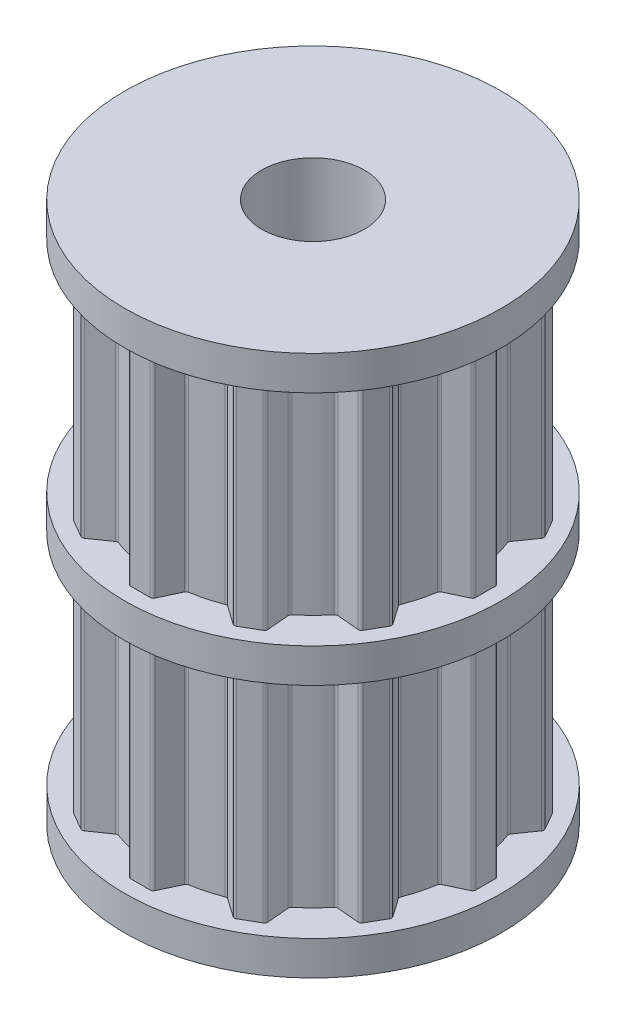
from build123d import *

# Parameters (mm, degrees)
SKETCH_1_R                       = 8.81
EXTRUDE_1_DEPTH                  = 13.8
EXTRUDE_5_DEPTH                  = 27.6
FILLET_1_R                       = 0.19
PATTERN_CIRCULAR_1_COUNT         = 12
FILLET_1_OF_PATTERN_CIRCULAR_1_R = 0.19
SKETCH_3_R                       = 11
EXTRUDE_3_DEPTH                  = 2
SKETCH_4_R                       = 11
EXTRUDE_4_DEPTH                  = 2
SKETCH_5_R                       = 3
CUT_EXTRUDE_1_DEPTH              = 32.6
EXTRUDE_START                    = -15.8
SKETCH_8_R                       = 11
EXTRUDE_6_DEPTH                  = 1


with BuildPart() as part:
    # 草圖1 → 填料-伸長1 (new body, symmetric)
    with BuildSketch(Plane(origin=(0, 0, 0), x_dir=(1, 0, 0), z_dir=(0, 1, 0))):
        Circle(SKETCH_1_R)
    extrude(amount=EXTRUDE_1_DEPTH, both=True)

    # 草圖7 → 填料-伸長5 (add, through all)
    with BuildSketch(Plane.XZ.offset(13.8)):
        Polygon((-1.751307658, -7.81), (1.751307658, -7.81), (0.692789274, -10.08), (-0.692789274, -10.08), align=None)
    extrude_5 = extrude(amount=-EXTRUDE_5_DEPTH)

    # 圓角1
    fillet_1_edges = [part.edges().sort_by_distance(p)[0] for p in [
        (-0.692789274, 0, -10.08),
        (1.332243049, 0, -8.708686954),
        (0.692789274, 0, -10.08),
        (-1.332243049, 0, -8.708686954),
    ]]
    fillet(fillet_1_edges, radius=FILLET_1_R)

    # 環狀複製排列1: 填料-伸長5 ×12 about axis
    pattern_circular_1_axis = Axis((0, 0, 0), (0, 1, 0))
    for i in range(1, PATTERN_CIRCULAR_1_COUNT):
        add(extrude_5.rotate(pattern_circular_1_axis, i * 360 / PATTERN_CIRCULAR_1_COUNT))

    # 圓角1 of 環狀複製排列1
    fillet_1_of_pattern_circular_1_edges = [part.edges().sort_by_distance(p)[0] for p in [
        (-5.639973111, 0, -8.383141433),
        (-3.200587152, 0, -8.20806566),
        (-4.440026889, 0, -9.075930707),
        (-5.508099802, 0, -6.875822611),
        (-9.075930707, 0, -4.440026889),
        (-6.875822611, 0, -5.508099802),
        (-8.383141433, 0, -5.639973111),
        (-8.20806566, 0, -3.200587152),
        (-10.08, 0, 0.692789274),
        (-8.708686954, 0, -1.332243049),
        (-10.08, 0, -0.692789274),
        (-8.708686954, 0, 1.332243049),
        (-8.383141433, 0, 5.639973111),
        (-8.20806566, 0, 3.200587152),
        (-9.075930707, 0, 4.440026889),
        (-6.875822611, 0, 5.508099802),
        (-4.440026889, 0, 9.075930707),
        (-5.508099802, 0, 6.875822611),
        (-5.639973111, 0, 8.383141433),
        (-3.200587152, 0, 8.20806566),
        (0.692789274, 0, 10.08),
        (-1.332243049, 0, 8.708686954),
        (-0.692789274, 0, 10.08),
        (1.332243049, 0, 8.708686954),
        (5.639973111, 0, 8.383141433),
        (3.200587152, 0, 8.20806566),
        (4.440026889, 0, 9.075930707),
        (5.508099802, 0, 6.875822611),
        (9.075930707, 0, 4.440026889),
        (6.875822611, 0, 5.508099802),
        (8.383141433, 0, 5.639973111),
        (8.20806566, 0, 3.200587152),
        (10.08, 0, -0.692789274),
        (8.708686954, 0, 1.332243049),
        (10.08, 0, 0.692789274),
        (8.708686954, 0, -1.332243049),
        (8.383141433, 0, -5.639973111),
        (8.20806566, 0, -3.200587152),
        (9.075930707, 0, -4.440026889),
        (6.875822611, 0, -5.508099802),
        (4.440026889, 0, -9.075930707),
        (5.508099802, 0, -6.875822611),
        (5.639973111, 0, -8.383141433),
        (3.200587152, 0, -8.20806566),
    ]]
    fillet(fillet_1_of_pattern_circular_1_edges, radius=FILLET_1_OF_PATTERN_CIRCULAR_1_R)

    # 草圖3 → 填料-伸長3 (add)
    with BuildSketch(Plane.XZ.offset(13.8)):
        Circle(SKETCH_3_R)
    extrude(amount=EXTRUDE_3_DEPTH)

    # 草圖4 → 填料-伸長4 (add)
    with BuildSketch(Plane(origin=(0, 13.8, 0), x_dir=(1, 0, 0), z_dir=(0, 1, 0))):
        Circle(SKETCH_4_R)
    extrude(amount=EXTRUDE_4_DEPTH)

    # 草圖5 → 除料-伸長1 (cut, through all)
    with BuildSketch(Plane.XZ.offset(15.8)):
        Circle(SKETCH_5_R)
    extrude(amount=-CUT_EXTRUDE_1_DEPTH, mode=Mode.SUBTRACT)

    # 草圖8 → 填料-伸長6 (add, symmetric)
    with BuildSketch(Plane(origin=(0, 15.8, 0), x_dir=(1, 0, 0), z_dir=(0, 1, 0)).offset(EXTRUDE_START)):
        Circle(SKETCH_8_R)
    extrude(amount=EXTRUDE_6_DEPTH, both=True)


solid = part.part
